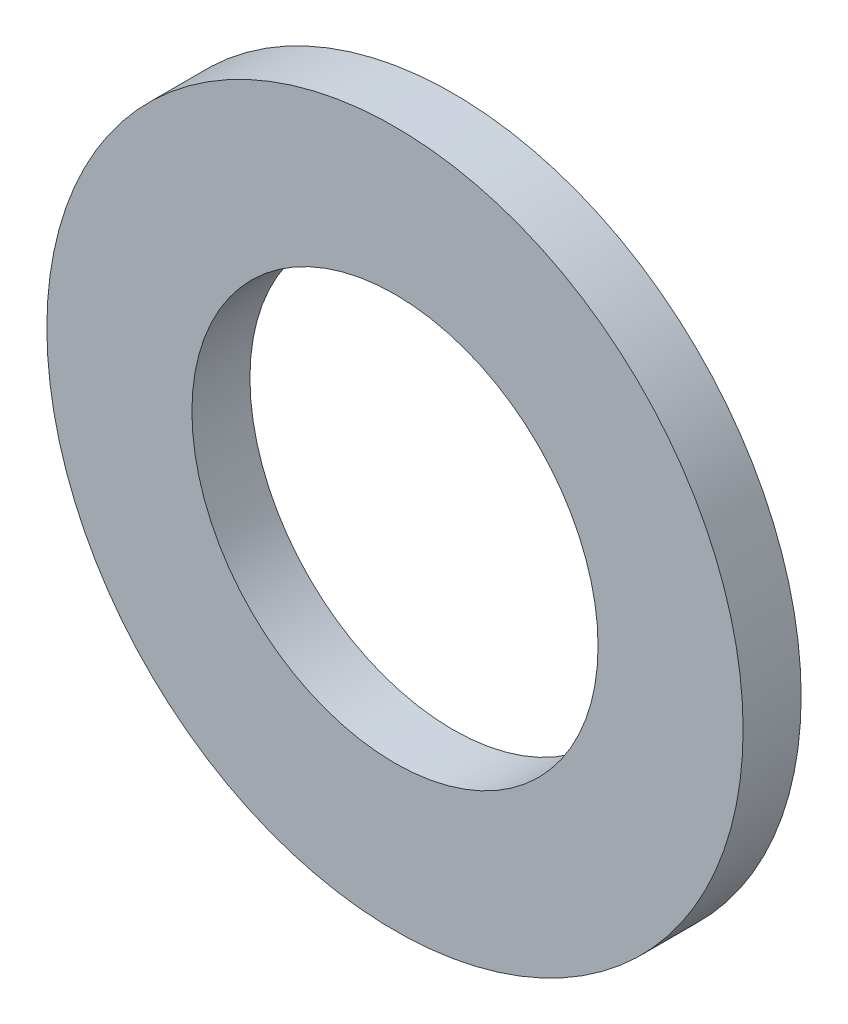
from build123d import *

# Parameters (mm, degrees)
SKETCH_1_R      = 15
SKETCH_1_R_2    = 8.75
EXTRUDE_1_DEPTH = 2.5


with BuildPart() as part:
    # 草图1 → 凸台-拉伸1 (new body)
    with BuildSketch(Plane.XY):
        Circle(SKETCH_1_R)
        Circle(SKETCH_1_R_2, mode=Mode.SUBTRACT)
    extrude(amount=EXTRUDE_1_DEPTH)


solid = part.part
